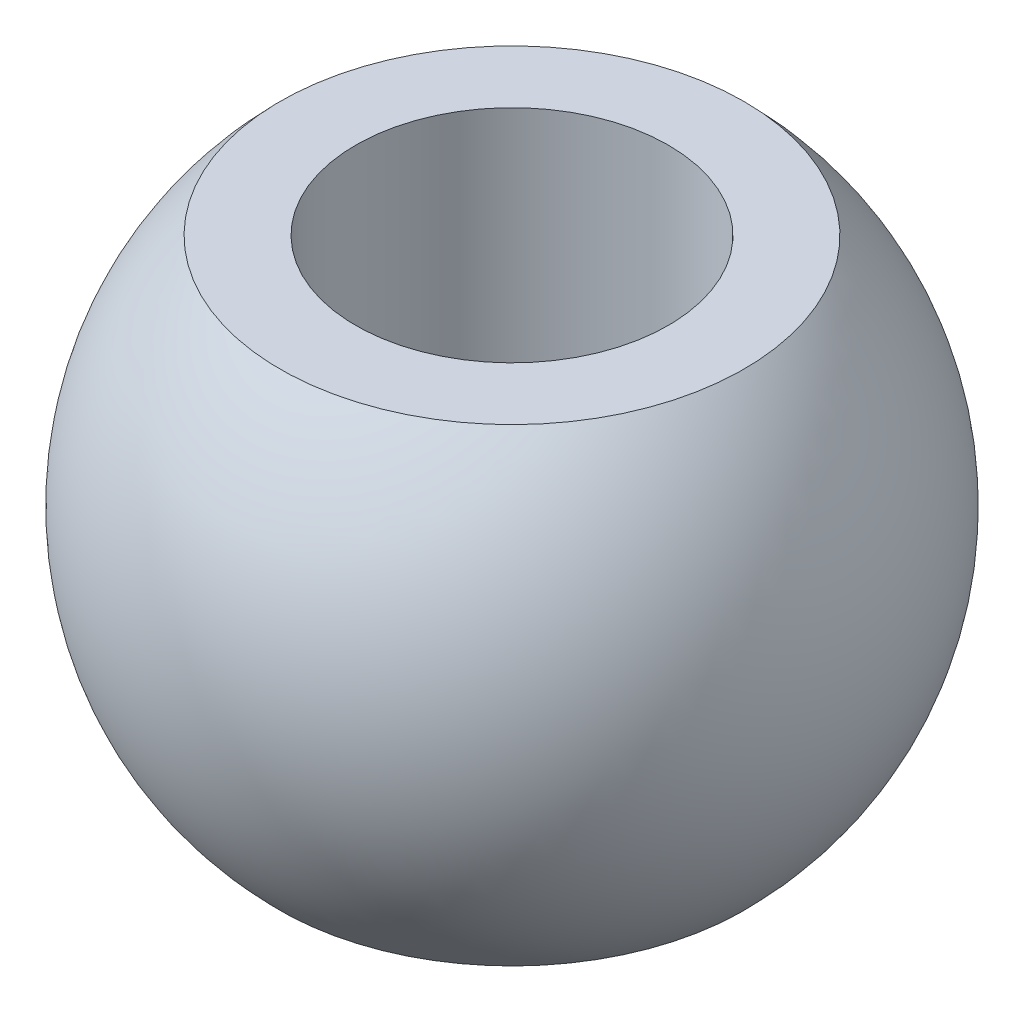
from build123d import *


with BuildPart() as part:
    # Szkic1 → Obrót1 (revolve)
    with BuildSketch(Plane.XY):
        with BuildLine():
            Line((3, -4.5), (3, 4.5))
            Line((3, 4.5), (4.451842315, 4.5))
            ThreePointArc((4.451842315, 4.5), (6.33, 0), (4.451842315, -4.5))
            Line((4.451842315, -4.5), (3, -4.5))
        make_face()
    revolve(axis=Axis((0, -11.1, 0), (0, 1, 0)))


solid = part.part
